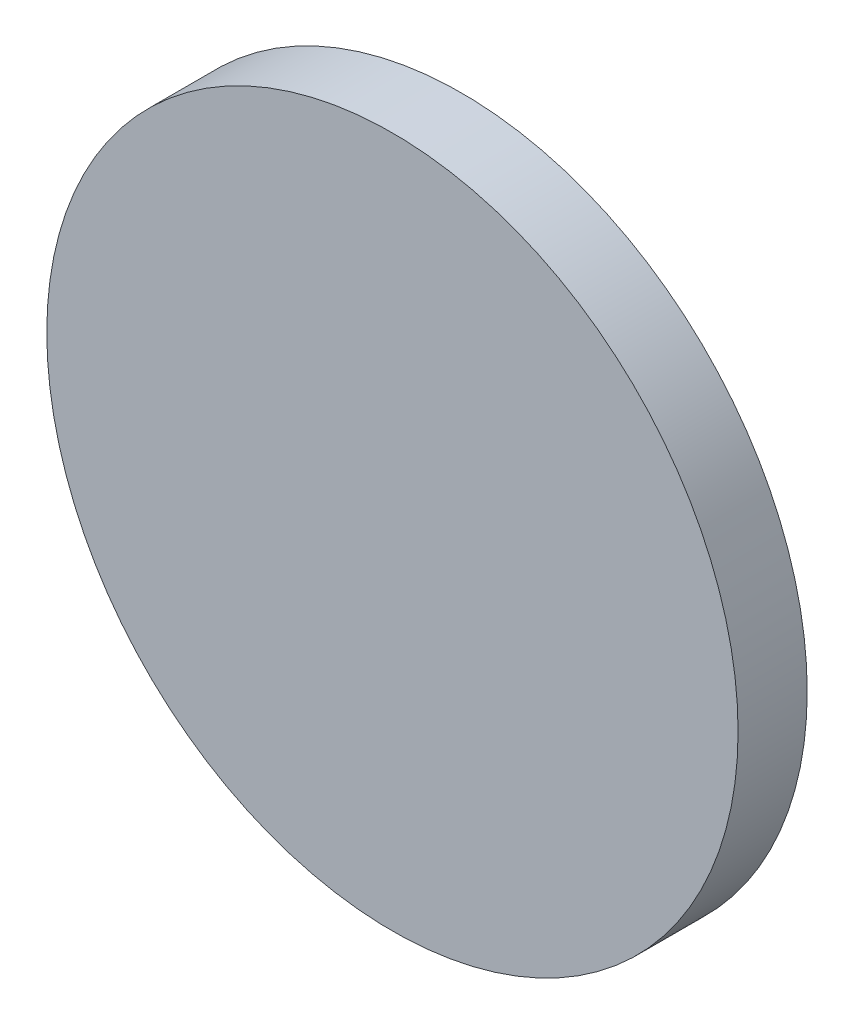
from build123d import *

# Parameters (mm, degrees)
SKETCH1_R           = 31.75
BOSS_EXTRUDE1_DEPTH = 6.35


with BuildPart() as part:
    # Sketch1 → Boss-Extrude1 (new body)
    with BuildSketch(Plane.XY):
        Circle(SKETCH1_R)
    extrude(amount=BOSS_EXTRUDE1_DEPTH)


solid = part.part
